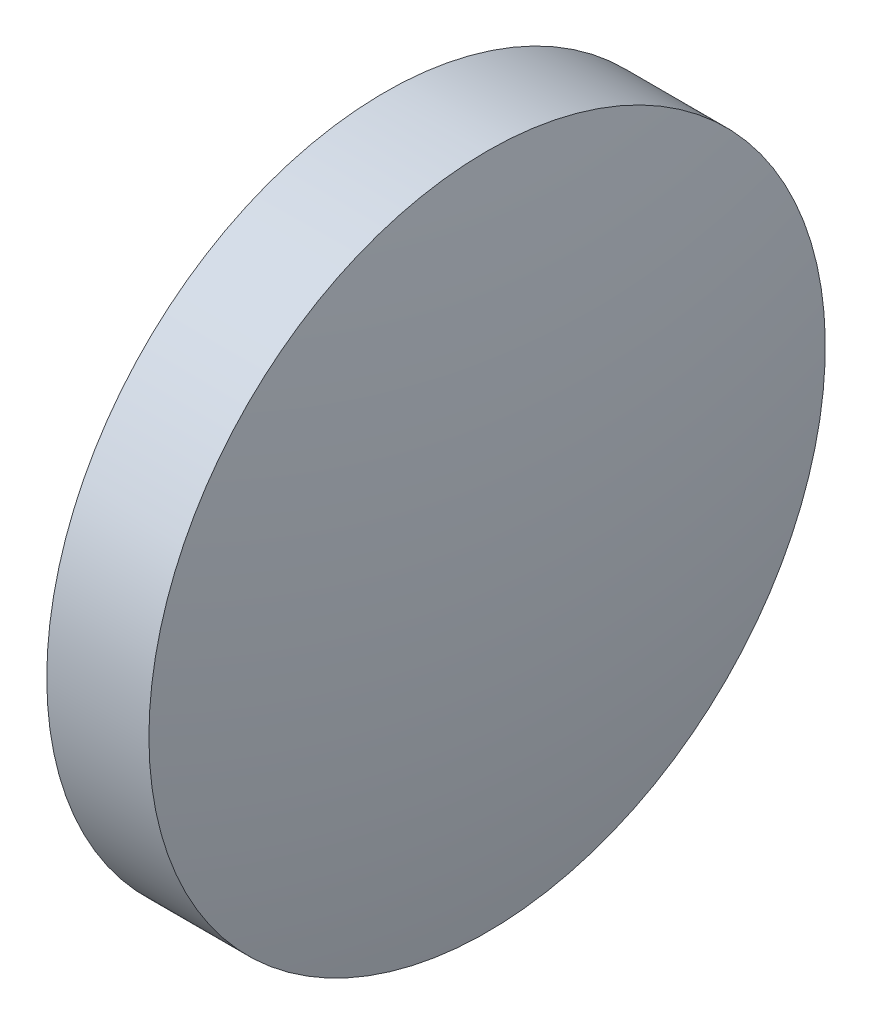
from build123d import *


with BuildPart() as part:
    # 草图2 → 旋转2 (revolve)
    with BuildSketch(Plane.XY):
        with BuildLine():
            Line((463.365589572, 129.06402577), (463.365589572, 134.06402577))
            Line((463.365589572, 134.06402577), (464.875589572, 134.06402577))
            ThreePointArc((464.875589572, 134.06402577), (465.242796853, 131.576002084), (465.365589572, 129.06402577))
            Line((465.365589572, 129.06402577), (463.365589572, 129.06402577))
        make_face()
    revolve(axis=Axis((462.567917318, 129.06402577, 0), (1, 0, 0)))


solid = part.part
